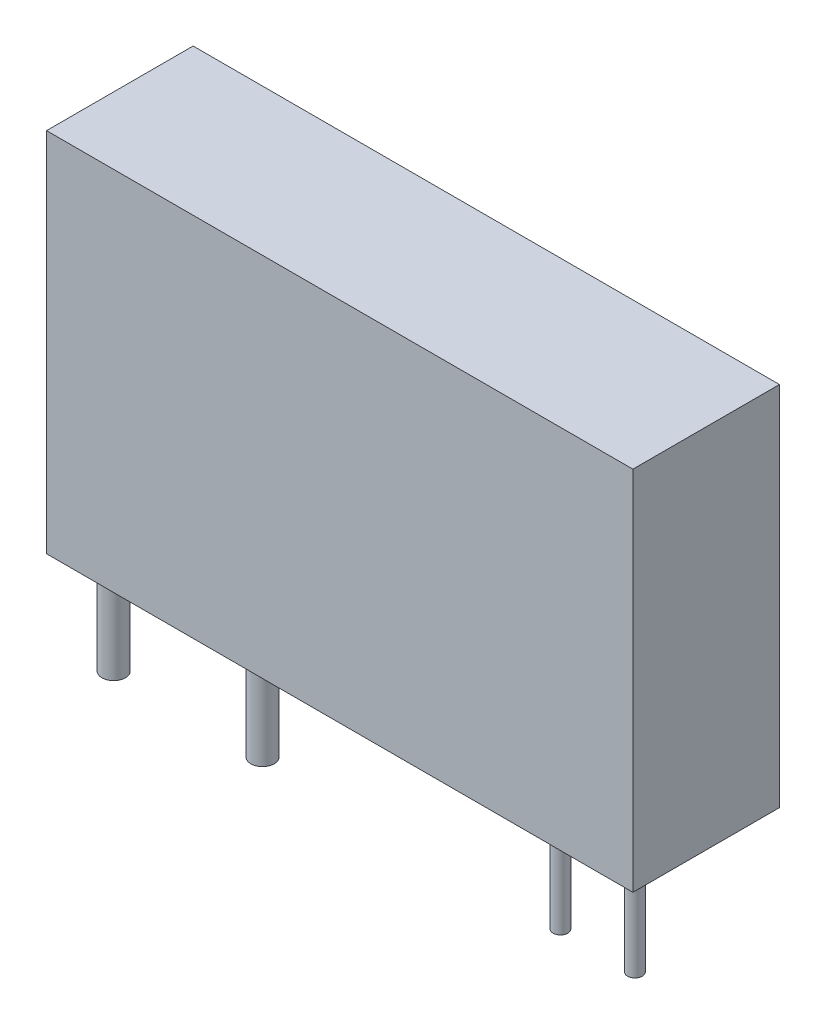
from build123d import *

# Parameters (mm, degrees)
CROQUIS1_W              = 20
CROQUIS1_H              = 5
SALIENTE_EXTRUIR1_DEPTH = 12.5
CROQUIS4_R              = 0.4
CROQUIS4_R_2            = 0.25
SALIENTE_EXTRUIR3_DEPTH = 3.5


with BuildPart() as part:
    # Croquis1 → Saliente-Extruir1 (new body)
    with BuildSketch(Plane(origin=(0, 0, 0), x_dir=(1, 0, 0), z_dir=(0, 1, 0))):
        Rectangle(CROQUIS1_W, CROQUIS1_H)
    extrude(amount=SALIENTE_EXTRUIR1_DEPTH)

    # Croquis4 → Saliente-Extruir3 (add)
    with BuildSketch(Plane.XZ):
        with Locations((-8.89, 1.32)):
            Circle(CROQUIS4_R)
        with Locations((-3.81, 1.32)):
            Circle(CROQUIS4_R)
        with Locations((6.35, 1.32)):
            Circle(CROQUIS4_R_2)
        with Locations((8.89, 1.32)):
            Circle(CROQUIS4_R_2)
    extrude(amount=SALIENTE_EXTRUIR3_DEPTH)


solid = part.part
